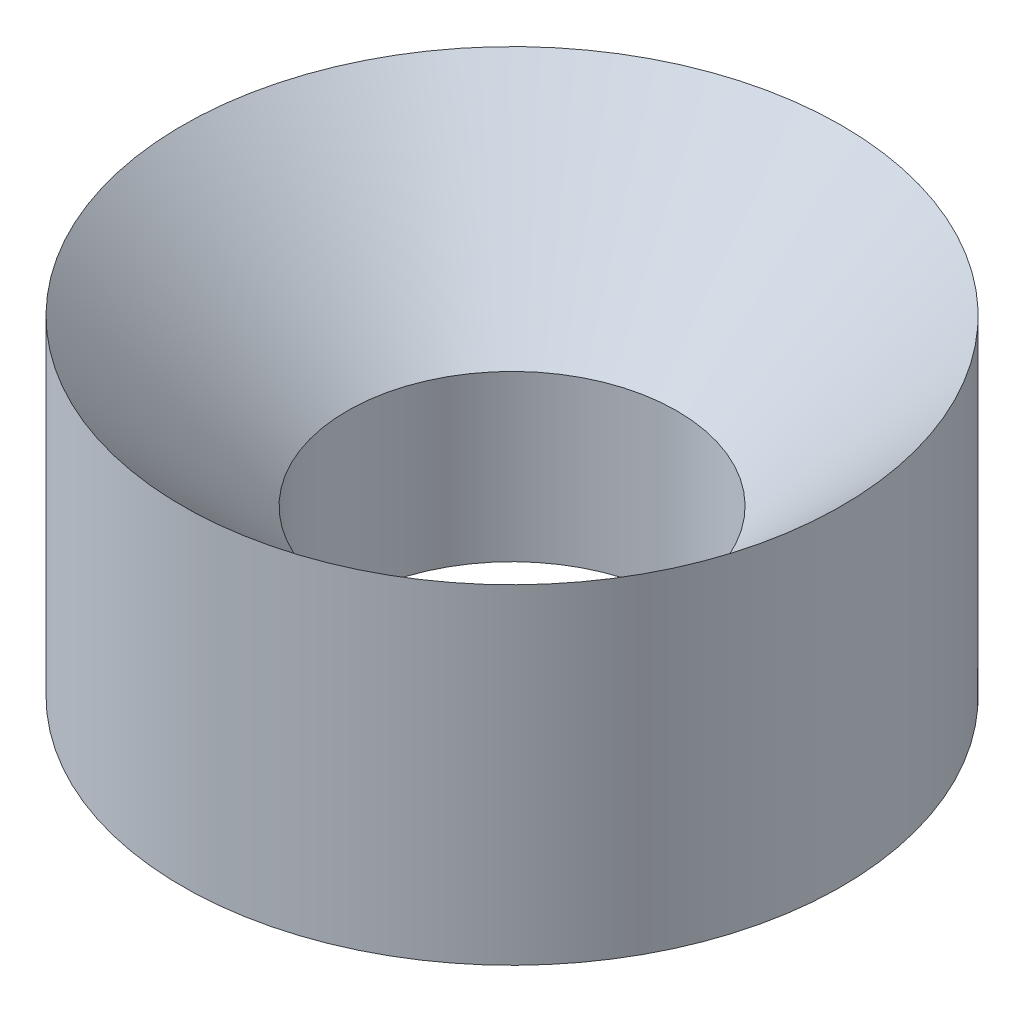
from build123d import *


with BuildPart() as part:
    # Sketch3 → Revolve1 (revolve)
    with BuildSketch(Plane(origin=(0, 0, 0), x_dir=(0, 0, -1), z_dir=(1, 0, 0))):
        Polygon((0, 0), (0, 40), (-20, 20), (-20, 0), align=None)
    revolve(axis=Axis((0, 0, 40), (0, 1, 0)))


solid = part.part
